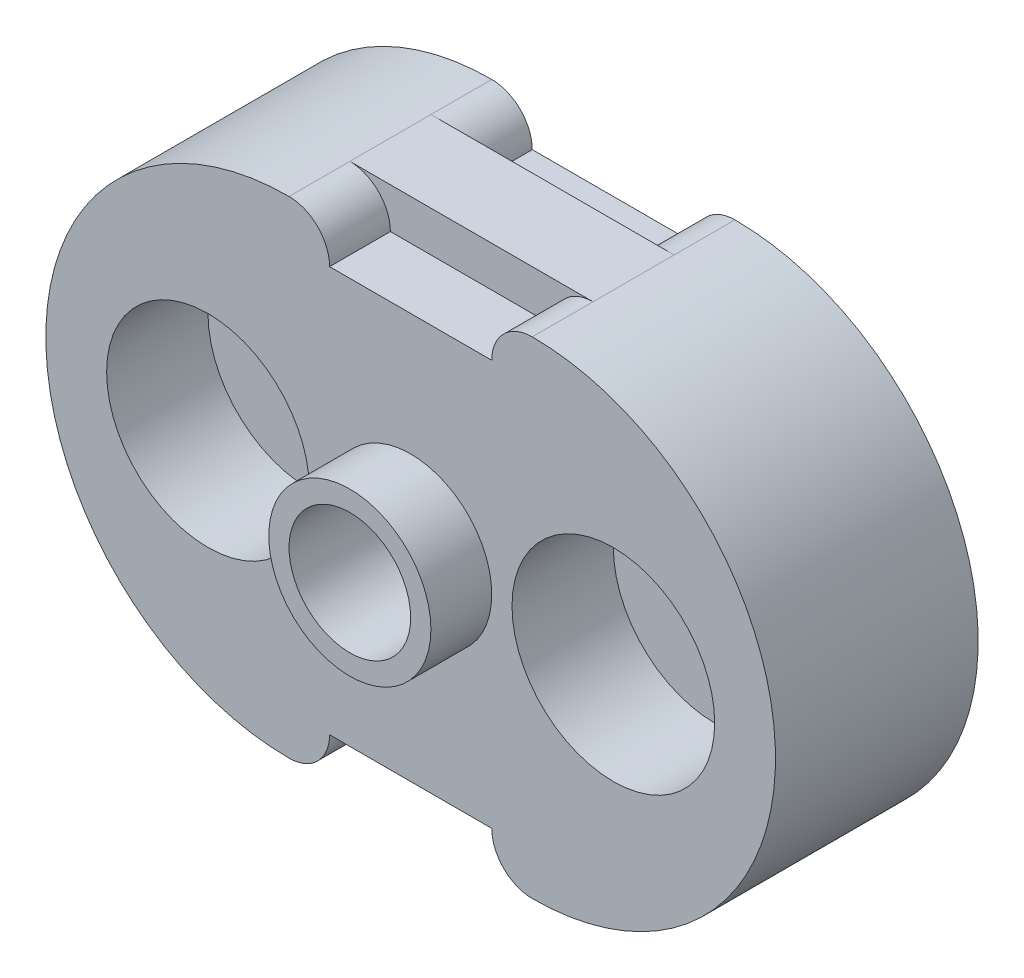
from build123d import *

# Parameters (mm, degrees)
BOSS_EXTRUDE1_DEPTH = 10
BOSS_EXTRUDE2_DEPTH = 7.5
BOSS_EXTRUDE3_DEPTH = 7.5
CUT_EXTRUDE1_DEPTH  = 7.5
SKETCH5_R           = 12.5
CUT_EXTRUDE3_DEPTH  = 12.5
SKETCH6_R           = 5
CUT_EXTRUDE4_DEPTH  = 17.5
SKETCH7_R           = 10
BOSS_EXTRUDE4_DEPTH = 7.5
SKETCH8_R           = 7.5
CUT_EXTRUDE5_DEPTH  = 25
SKETCH10_R          = 15
BOSS_EXTRUDE6_DEPTH = 15
SKETCH11_R          = 7.5
CUT_EXTRUDE6_DEPTH  = 20


with BuildPart() as part:
    # Sketch1 → Boss-Extrude1 (new body)
    with BuildSketch(Plane.XY):
        with BuildLine():
            Line((-30, 60), (0, 60))
            ThreePointArc((0, 60), (30, 30), (0, 0))
            Line((0, 0), (-30, 0))
            ThreePointArc((-30, 0), (-60, 30), (-30, 60))
        make_face()
    extrude(amount=BOSS_EXTRUDE1_DEPTH)

    # Sketch2 → Boss-Extrude2 (add)
    with BuildSketch(Plane.XY.offset(10)):
        with BuildLine():
            Line((-25, 55), (-5, 55))
            ThreePointArc((-5, 55), (-3.535533906, 58.535533906), (0, 60))
            ThreePointArc((0, 60), (30, 30), (0, 0))
            ThreePointArc((0, 0), (-3.535533906, 1.464466094), (-5, 5))
            Line((-5, 5), (-25, 5))
            ThreePointArc((-25, 5), (-26.464466094, 1.464466094), (-30, 0))
            ThreePointArc((-30, 0), (-60, 30), (-30, 60))
            ThreePointArc((-30, 60), (-26.464466094, 58.535533906), (-25, 55))
        make_face()
    extrude(amount=BOSS_EXTRUDE2_DEPTH)

    # Sketch3 → Boss-Extrude3 (add)
    with BuildSketch(Plane(origin=(0, 0, 0), x_dir=(-1, 0, 0), z_dir=(0, 0, -1))):
        with BuildLine():
            Line((5, 55), (25, 55))
            ThreePointArc((25, 55), (26.464466094, 58.535533906), (30, 60))
            ThreePointArc((30, 60), (60, 30), (30, 0))
            ThreePointArc((30, 0), (26.464466094, 1.464466094), (25, 5))
            Line((25, 5), (5, 5))
            ThreePointArc((5, 5), (3.535533906, 1.464466094), (0, 0))
            ThreePointArc((0, 0), (-30, 30), (0, 60))
            ThreePointArc((0, 60), (3.535533906, 58.535533906), (5, 55))
        make_face()
    extrude(amount=BOSS_EXTRUDE3_DEPTH)

    # Sketch4 → Cut-Extrude1 (cut)
    with BuildSketch(Plane(origin=(0, 0, -7.5), x_dir=(-1, 0, 0), z_dir=(0, 0, -1))):
        with BuildLine():
            Line((-5, 50), (35, 50))
            ThreePointArc((35, 50), (55, 30), (35, 10))
            Line((35, 10), (-5, 10))
            ThreePointArc((-5, 10), (-25, 30), (-5, 50))
        make_face()
    extrude(amount=-CUT_EXTRUDE1_DEPTH, mode=Mode.SUBTRACT)

    # Sketch5 → Cut-Extrude3 (cut)
    with BuildSketch(Plane.XY.offset(17.5)):
        with Locations((10, 30)):
            Circle(SKETCH5_R)
        with Locations((-40, 30)):
            Circle(SKETCH5_R)
    extrude(amount=-CUT_EXTRUDE3_DEPTH, mode=Mode.SUBTRACT)

    # Sketch6 → Cut-Extrude4 (cut)
    with BuildSketch(Plane.XY.offset(5)):
        with Locations((10, 30)):
            Circle(SKETCH6_R)
        with Locations((-40, 30)):
            Circle(SKETCH6_R)
    extrude(amount=-CUT_EXTRUDE4_DEPTH, mode=Mode.SUBTRACT)

    # Sketch7 → Boss-Extrude4 (add)
    with BuildSketch(Plane.XY.offset(17.5)):
        with Locations((-15, 30)):
            Circle(SKETCH7_R)
    extrude(amount=BOSS_EXTRUDE4_DEPTH)

    # Sketch8 → Cut-Extrude5 (cut)
    with BuildSketch(Plane.XY.offset(25)):
        with Locations((-15, 30)):
            Circle(SKETCH8_R)
    extrude(amount=-CUT_EXTRUDE5_DEPTH, mode=Mode.SUBTRACT)

    # Sketch10 → Boss-Extrude6 (add)
    with BuildSketch(Plane(origin=(0, 0, 0), x_dir=(-1, 0, 0), z_dir=(0, 0, -1))):
        with Locations((15, 30)):
            Circle(SKETCH10_R)
    extrude(amount=BOSS_EXTRUDE6_DEPTH)

    # Sketch11 → Cut-Extrude6 (cut)
    with BuildSketch(Plane(origin=(0, 0, -15), x_dir=(-1, 0, 0), z_dir=(0, 0, -1))):
        with Locations((15, 30)):
            Circle(SKETCH11_R)
    extrude(amount=-CUT_EXTRUDE6_DEPTH, mode=Mode.SUBTRACT)


solid = part.part
